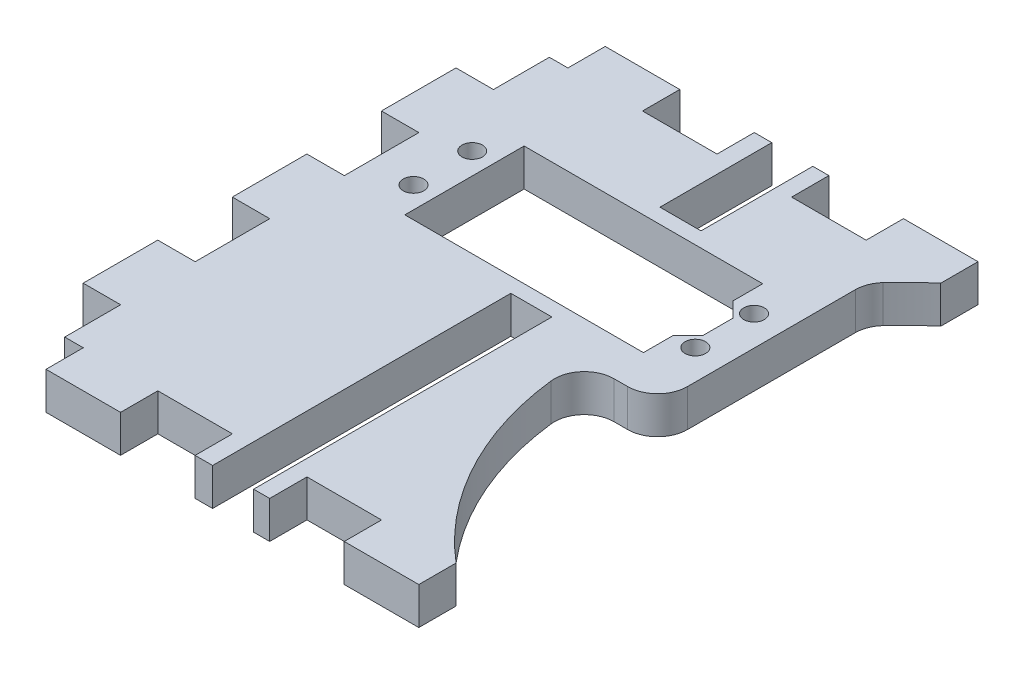
from build123d import *

# Parameters (mm, degrees)
SKETCH2_W           = 73.039929049
SKETCH2_H           = 6.35
BOSS_EXTRUDE1_DEPTH = 95.25
SKETCH3_R           = 1.75
CUT_EXTRUDE1_DEPTH  = 7.35
CUT_EXTRUDE2_DEPTH  = 7.35
FILLET1_R           = 5.08
SKETCH8_W           = 6.990804807
SKETCH8_H           = 19.05
SKETCH8_H_2         = 50.8
CUT_EXTRUDE3_DEPTH  = 7.35
SKETCH9_W           = 12.7
SKETCH9_H           = 6.35
CUT_EXTRUDE4_DEPTH  = 7.35
LPATTERN1_COUNT     = 8
LPATTERN1_PITCH     = 25.4
SKETCH10_W          = 6.379369351
SKETCH10_H          = 15.875
SKETCH10_H_2        = 12.7
CUT_EXTRUDE5_DEPTH  = 7.35


with BuildPart() as part:
    # Sketch2 → Boss-Extrude1 (new body)
    with BuildSketch(Plane.XY):
        with Locations((40.188577261, 34.925)):
            Rectangle(SKETCH2_W, SKETCH2_H)
    extrude(amount=BOSS_EXTRUDE1_DEPTH)

    # Sketch3 → Cut-Extrude1 (cut, through all)
    with BuildSketch(Plane(origin=(0, 38.1, 0), x_dir=(1, 0, 0), z_dir=(0, 1, 0))):
        with Locations((17.308541785, -26.75)):
            Circle(SKETCH3_R)
        with Locations((17.308541785, -36.75)):
            Circle(SKETCH3_R)
        with Locations((65.308541785, -36.75)):
            Circle(SKETCH3_R)
        with Locations((65.308541785, -26.75)):
            Circle(SKETCH3_R)
        Polygon((64.168541785, -29.21), (64.168541785, -34.29), (61.628541785, -36.83), (61.628541785, -41.91), (20.988541785, -41.91), (20.988541785, -21.59), (61.628541785, -21.59), (61.628541785, -26.67), align=None)
    extrude(amount=-CUT_EXTRUDE1_DEPTH, mode=Mode.SUBTRACT)

    # Sketch6 → Cut-Extrude2 (cut, through all)
    with BuildSketch(Plane(origin=(0, 38.1, 0), x_dir=(1, 0, 0), z_dir=(0, 1, 0))):
        with BuildLine():
            Line((57.56896905, -48.26), (70.388541785, -48.26))
            Line((70.388541785, -48.26), (70.388541785, -12.664576304))
            ThreePointArc((70.388541785, -12.664576304), (73.417894551, -9.376528703), (76.708541785, -6.35))
            Line((76.708541785, -6.35), (76.708541785, -88.9))
            ThreePointArc((76.708541785, -88.9), (62.718427414, -70.661771391), (57.56896905, -48.26))
        make_face()
    extrude(amount=-CUT_EXTRUDE2_DEPTH, mode=Mode.SUBTRACT)

    # Fillet1
    fillet1_edges = [part.edges().sort_by_distance(p)[0] for p in [
        (57.56896905, 34.925, 48.26),
        (70.388541785, 34.925, 48.26),
        (70.388541785, 34.925, 12.664576304),
    ]]
    fillet(fillet1_edges, radius=FILLET1_R)

    # Sketch8 → Cut-Extrude3 (cut, through all)
    with BuildSketch(Plane(origin=(0, 38.1, 0), x_dir=(1, 0, 0), z_dir=(0, 1, 0))):
        with Locations((45.079952064, -9.525)):
            Rectangle(SKETCH8_W, SKETCH8_H)
        with Locations((45.079952064, -69.85)):
            Rectangle(SKETCH8_W, SKETCH8_H_2)
    extrude(amount=-CUT_EXTRUDE3_DEPTH, mode=Mode.SUBTRACT)

    # Sketch9 → Cut-Extrude4 (cut, through all)
    with BuildSketch(Plane(origin=(0, 38.1, 0), x_dir=(1, 0, 0), z_dir=(0, 1, 0))):
        with Locations((57.658541785, -3.175)):
            Rectangle(SKETCH9_W, SKETCH9_H)
        with Locations((57.658541785, -92.075)):
            Rectangle(SKETCH9_W, SKETCH9_H)
    cut_extrude4 = extrude(amount=-CUT_EXTRUDE4_DEPTH, mode=Mode.SUBTRACT)

    # LPattern1: Cut-Extrude4 ×8
    with Locations(*[(-i * LPATTERN1_PITCH, 0, 0) for i in range(1, LPATTERN1_COUNT)]):
        add(cut_extrude4, mode=Mode.SUBTRACT)

    # Sketch10 → Cut-Extrude5 (cut, through all)
    with BuildSketch(Plane(origin=(0, 38.1, 0), x_dir=(1, 0, 0), z_dir=(0, 1, 0))):
        with Locations((6.858297412, -7.9375)):
            Rectangle(SKETCH10_W, SKETCH10_H)
        with Locations((6.858297412, -87.3125)):
            Rectangle(SKETCH10_W, SKETCH10_H)
        with Locations((6.858297412, -60.325)):
            Rectangle(SKETCH10_W, SKETCH10_H_2)
        with Locations((6.858297412, -34.925)):
            Rectangle(SKETCH10_W, SKETCH10_H_2)
    extrude(amount=-CUT_EXTRUDE5_DEPTH, mode=Mode.SUBTRACT)


solid = part.part
